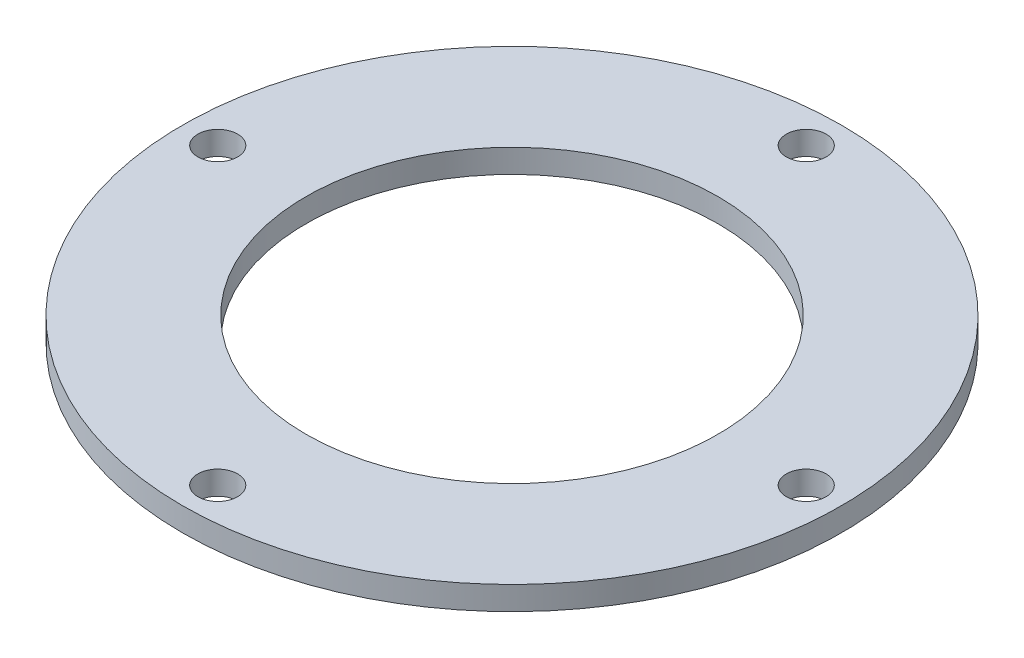
from build123d import *

# Parameters (mm, degrees)
ESQUISSE1_R        = 56
ESQUISSE1_R_2      = 3.375
ESQUISSE1_R_3      = 35
BOSS_EXTRU_1_DEPTH = 4


with BuildPart() as part:
    # Esquisse1 → Boss.-Extru.1 (new body)
    with BuildSketch(Plane(origin=(0, 0, 0), x_dir=(1, 0, 0), z_dir=(0, 1, 0))):
        with Locations(Location((0, 0, 0), (0, 0, 270))):  # turned: the seam where the file's is
            Circle(ESQUISSE1_R)
        with Locations(Location((-50, 0, 0), (0, 0, 270))):  # turned: the seam where the file's is
            Circle(ESQUISSE1_R_2, mode=Mode.SUBTRACT)
        with Locations(Location((0, -50, 0), (0, 0, 270))):  # turned: the seam where the file's is
            Circle(ESQUISSE1_R_2, mode=Mode.SUBTRACT)
        with Locations(Location((50, 0, 0), (0, 0, 270))):  # turned: the seam where the file's is
            Circle(ESQUISSE1_R_2, mode=Mode.SUBTRACT)
        with Locations(Location((0, 0, 0), (0, 0, 270))):  # turned: the seam where the file's is
            Circle(ESQUISSE1_R_3, mode=Mode.SUBTRACT)
        with Locations(Location((0, 50, 0), (0, 0, 270))):  # turned: the seam where the file's is
            Circle(ESQUISSE1_R_2, mode=Mode.SUBTRACT)
    extrude(amount=BOSS_EXTRU_1_DEPTH)


solid = part.part
